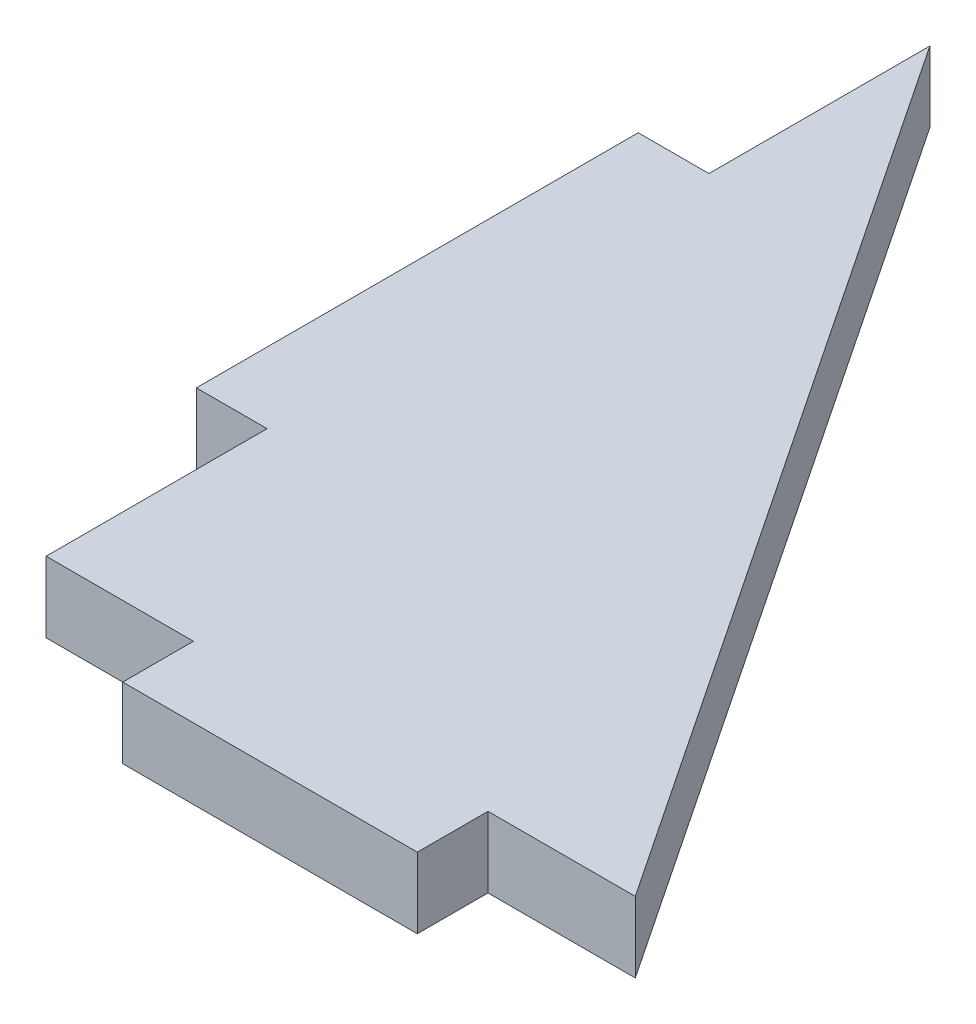
from build123d import *

# Parameters (mm, degrees)
SKETCH1_W           = 12
SKETCH1_H           = 75
SKETCH1_W_2         = 50
SKETCH1_H_2         = 12
BOSS_EXTRUDE1_DEPTH = 12


with BuildPart() as part:
    # Sketch1 → Boss-Extrude1 (new body)
    with BuildSketch(Plane(origin=(0, 0, 0), x_dir=(1, 0, 0), z_dir=(0, 1, 0))):
        with Locations((-6, 75)):
            Rectangle(SKETCH1_W, SKETCH1_H)
        Polygon((0, 37.5), (0, 0), (25, 0), (25, 12), (75, 12), (75, 0), (100, 0), (0, 150), (0, 112.5), (12, 112.5), (12, 37.5), align=None)
        with Locations((50, -6)):
            Rectangle(SKETCH1_W_2, SKETCH1_H_2)
        with Locations((50, 6)):
            Rectangle(SKETCH1_W_2, SKETCH1_H_2)
        with Locations((6, 75)):
            Rectangle(SKETCH1_W, SKETCH1_H)
    extrude(amount=BOSS_EXTRUDE1_DEPTH)


solid = part.part
